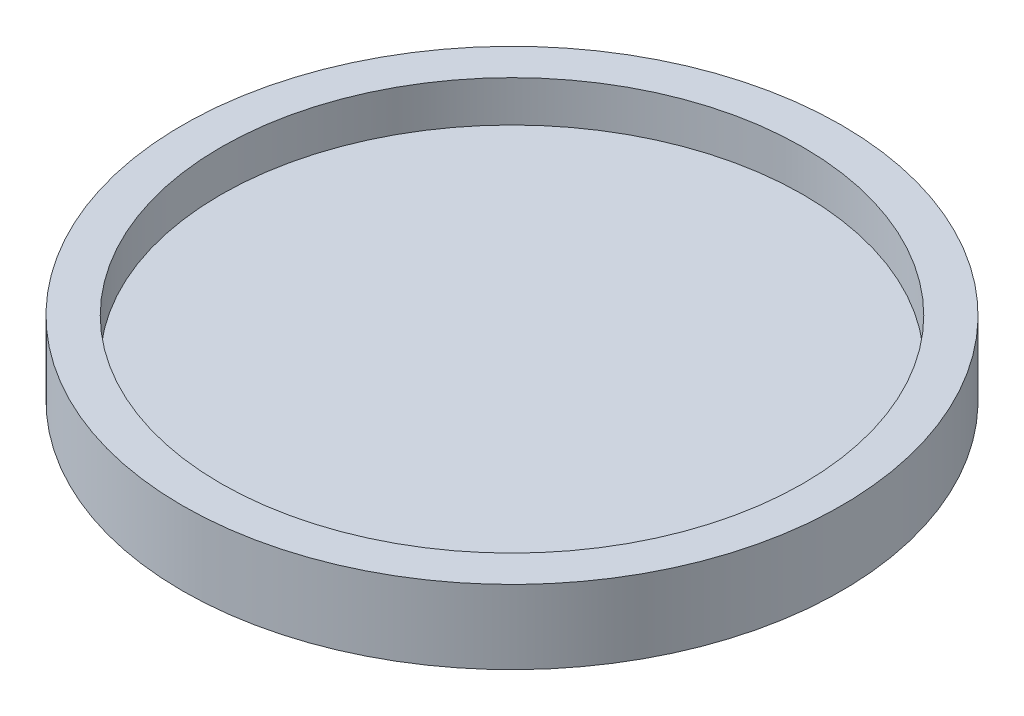
from build123d import *

# Parameters (mm, degrees)
SKETCH1_R           = 51.0286
SKETCH1_R_2         = 45.085
BOSS_EXTRUDE1_DEPTH = 6.35
SKETCH2_R           = 51.0286
BOSS_EXTRUDE2_DEPTH = 5.08


with BuildPart() as part:
    # Sketch1 → Boss-Extrude1 (new body)
    with BuildSketch(Plane(origin=(0, 0, 0), x_dir=(1, 0, 0), z_dir=(0, 1, 0))):
        Circle(SKETCH1_R)
        Circle(SKETCH1_R_2, mode=Mode.SUBTRACT)
    extrude(amount=BOSS_EXTRUDE1_DEPTH)

    # Sketch2 → Boss-Extrude2 (add)
    with BuildSketch(Plane.XZ):
        Circle(SKETCH2_R)
    extrude(amount=BOSS_EXTRUDE2_DEPTH)


solid = part.part
